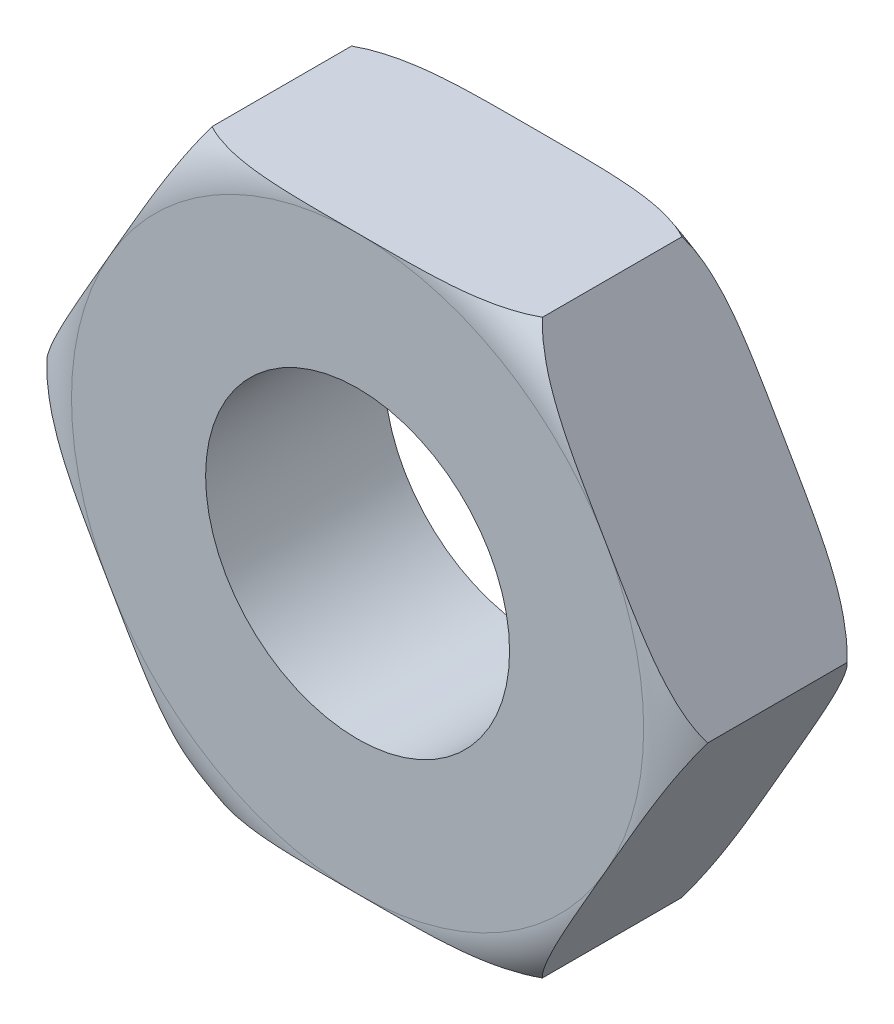
from build123d import *

# Parameters (mm, degrees)
ESQUISSE1_R        = 4.25
BOSS_EXTRU_1_DEPTH = 2.5


with BuildPart() as part:
    # Esquisse1 → Boss.-Extru.1 (new body, symmetric)
    with BuildSketch(Plane.XY):
        Polygon((-4.618802154, -8), (4.618802154, -8), (9.237604307, 0), (4.618802154, 8), (-4.618802154, 8), (-9.237604307, 0), align=None)
        Circle(ESQUISSE1_R, mode=Mode.SUBTRACT)
    extrude(amount=BOSS_EXTRU_1_DEPTH, both=True)

    # Esquisse3 → Enlèvement de matière-Révolution2 (revolve, cut)
    with BuildSketch(Plane(origin=(0, 0, 0), x_dir=(0, 0, -1), z_dir=(1, 0, 0)), mode=Mode.PRIVATE) as enl_vement_de_mati_re_r_volution2_sk:
        with BuildLine():
            Line((3, 10.101429963), (3, 8))
            Line((3, 8), (2.5, 8))
            ThreePointArc((2.5, 8), (2.166714284, 9.000572077), (1.3, 9.601429963))
            Line((1.3, 9.601429963), (1.3, 10.101429963))
            Line((1.3, 10.101429963), (3, 10.101429963))
        make_face()
    enl_vement_de_mati_re_r_volution2 = revolve(enl_vement_de_mati_re_r_volution2_sk.sketch.rotate(Axis((0, 0, 5.617054836), (0, 0, -1)), 90), axis=Axis((0, 0, 5.617054836), (0, 0, -1)), mode=Mode.SUBTRACT)  # turned: the seam where the file's is

    # Symétrie1: Enlèvement de matière-Révolution2 across plane
    add(enl_vement_de_mati_re_r_volution2.mirror(Plane.XY), mode=Mode.SUBTRACT)


solid = part.part
